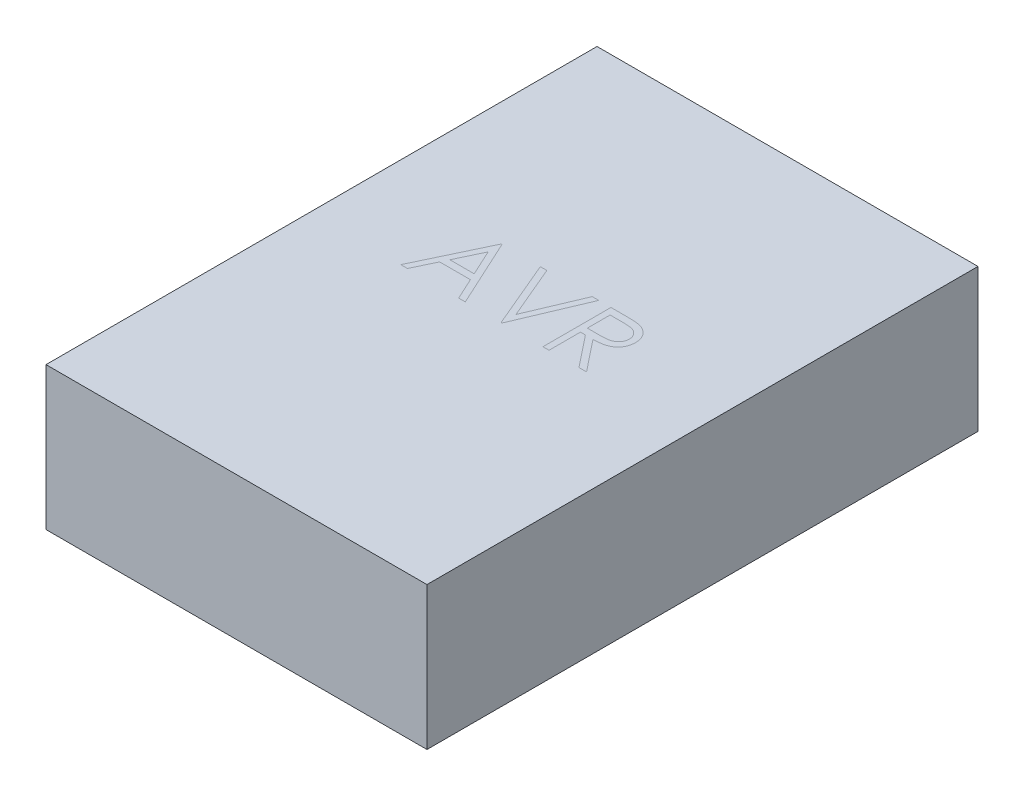
from build123d import *

# Parameters (mm, degrees)
SKETCH1_W           = 280
SKETCH1_H           = 405
BOSS_EXTRUDE1_DEPTH = 105


with BuildPart() as part:
    # Sketch1 → Boss-Extrude1 (new body)
    with BuildSketch(Plane(origin=(0, 0, 0), x_dir=(1, 0, 0), z_dir=(0, 1, 0))):
        Rectangle(SKETCH1_W, SKETCH1_H)
    extrude(amount=BOSS_EXTRUDE1_DEPTH)


solid = part.part
